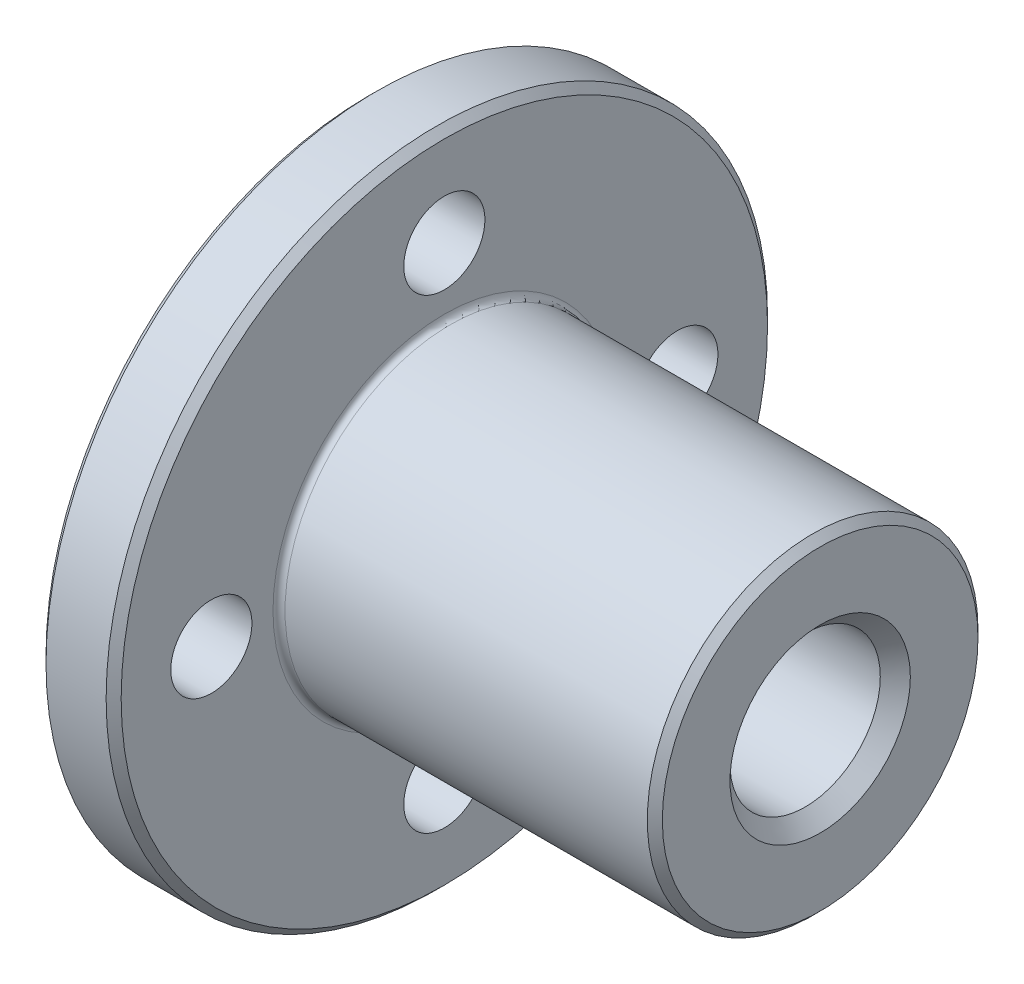
from build123d import *

# Parameters (mm, degrees)
SKETCH1_W      = 5
SKETCH1_H      = 22
SKETCH2_R      = 11
EXTRUDE1_DEPTH = 25
HOLEWZD1_D     = 5.4
HOLEWZD1_DEPTH = 5
HOLEWZD2_D     = 10
HOLEWZD2_DEPTH = 30
CHAMFER1_SIZE  = 0.5
CHAMFER2_SIZE  = 1
FILLET1_R      = 0.4


with BuildPart() as part:
    # Sketch1 → Revolve1 (revolve)
    with BuildSketch(Plane(origin=(0, 0, 0), x_dir=(-1, 0, 0), z_dir=(0, 0, -1))):
        with Locations((-2.5, 11)):
            Rectangle(SKETCH1_W, SKETCH1_H)
    revolve(axis=Axis((5, 0, 0), (-1, 0, 0)))

    # Sketch2 → Extrude1 (add)
    with BuildSketch(Plane(origin=(5, 0, 0), x_dir=(0, 0, -1), z_dir=(1, 0, 0))):
        Circle(SKETCH2_R)
    extrude(amount=EXTRUDE1_DEPTH)

    # HoleWzd1
    with Locations(Plane(origin=(5, 0, 0), x_dir=(0, 0, -1), z_dir=(1, 0, 0))):
        with Locations((0, -15.5), (15.5, 0), (-15.5, 0), (0, 15.5)):
            Hole(HOLEWZD1_D / 2, depth=HOLEWZD1_DEPTH)

    # HoleWzd2
    with Locations(Plane(origin=(30, 0, 0), x_dir=(0, 0, -1), z_dir=(1, 0, 0))):
        with Locations((0, 0)):
            Hole(HOLEWZD2_D / 2, depth=HOLEWZD2_DEPTH)

    # Chamfer1
    chamfer1_edges = [part.edges().sort_by_distance(p)[0] for p in [
        (0, -22, 0),
        (5, -22, 0),
        (30, 0, 11),
    ]]
    chamfer(chamfer1_edges, length=CHAMFER1_SIZE)

    # Chamfer2
    chamfer2_edges = [part.edges().sort_by_distance(p)[0] for p in [
        (30, 0, -5),
        (0, 0, -5),
    ]]
    chamfer(chamfer2_edges, length=CHAMFER2_SIZE)

    # Fillet1
    fillet1_edges = [part.edges().sort_by_distance(p)[0] for p in [
        (5, 0, 11),
    ]]
    fillet(fillet1_edges, radius=FILLET1_R)


solid = part.part
